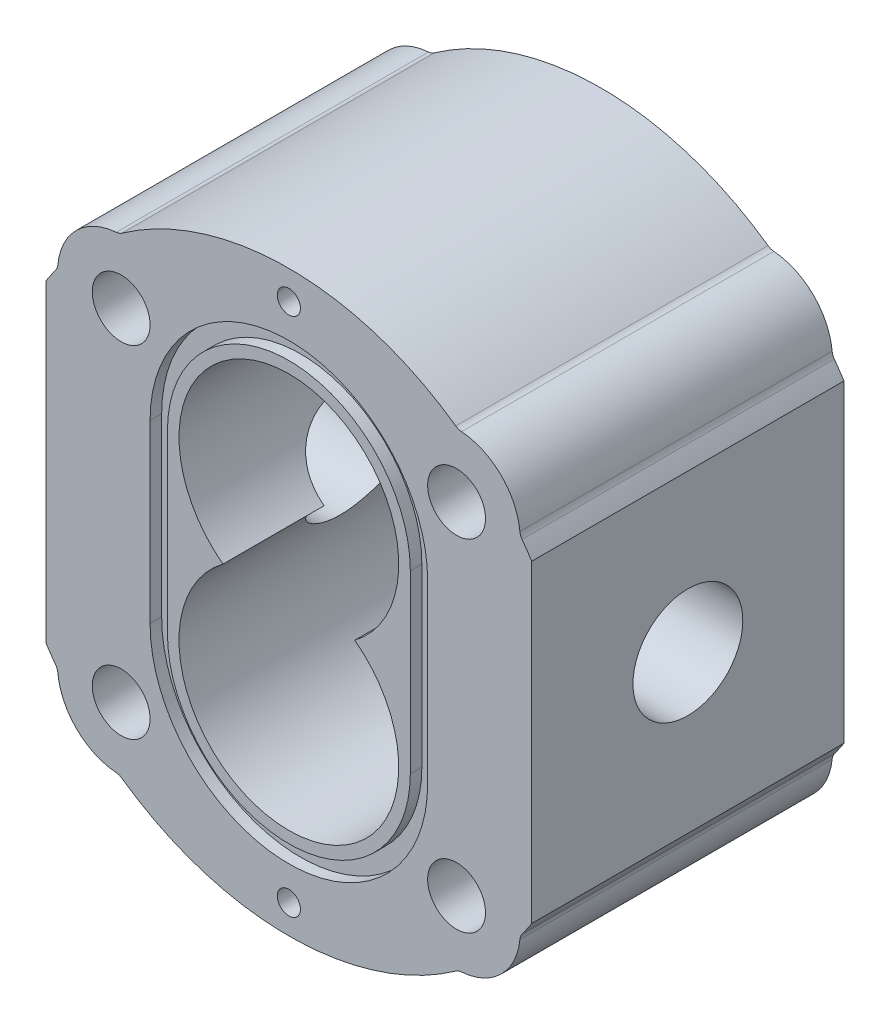
from build123d import *

# Parameters (mm, degrees)
SKETCH2_R           = 5
BOSS_EXTRUDE1_DEPTH = 27
SKETCH3_R           = 9.5
CUT_EXTRUDE2_DEPTH  = 85
CUT_EXTRUDE3_DEPTH  = 2
SKETCH6_R           = 2
CUT_EXTRUDE4_DEPTH  = 3


with BuildPart() as part:
    # Sketch2 → Boss-Extrude1 (new body, symmetric)
    with BuildSketch(Plane.XY):
        with BuildLine():
            ThreePointArc((-39.949803133, 15.349672018), (-36.711412809, 22.144368202), (-29.86235622, 25.266145255))
            ThreePointArc((-29.86235622, 25.266145255), (-29.339100999, 25.379156062), (-28.864565634, 25.626913314))
            ThreePointArc((-28.864565634, 25.626913314), (0, 34.8), (28.864565634, 25.626913314))
            ThreePointArc((28.864565634, 25.626913314), (29.339100999, 25.379156062), (29.86235622, 25.266145255))
            ThreePointArc((29.86235622, 25.266145255), (36.711412809, 22.144368202), (39.949803133, 15.349672018))
            ThreePointArc((39.949803133, 15.349672018), (40.071741311, 14.828424908), (40.32757349, 14.358193726))
            ThreePointArc((40.32757349, 14.358193726), (41.181697345, 13.15608936), (42, 11.929319933))
            Line((42, 11.929319933), (42, -42.329319933))
            ThreePointArc((42, -42.329319933), (41.181697345, -43.55608936), (40.32757349, -44.758193726))
            ThreePointArc((40.32757349, -44.758193726), (40.071741311, -45.228424908), (39.949803133, -45.749672018))
            ThreePointArc((39.949803133, -45.749672018), (36.711412809, -52.544368202), (29.86235622, -55.666145255))
            ThreePointArc((29.86235622, -55.666145255), (29.339100999, -55.779156062), (28.864565634, -56.026913314))
            ThreePointArc((28.864565634, -56.026913314), (0, -65.2), (-28.864565634, -56.026913314))
            ThreePointArc((-28.864565634, -56.026913314), (-29.339100999, -55.779156062), (-29.86235622, -55.666145255))
            ThreePointArc((-29.86235622, -55.666145255), (-36.711412809, -52.544368202), (-39.949803133, -45.749672018))
            ThreePointArc((-39.949803133, -45.749672018), (-40.071741311, -45.228424908), (-40.32757349, -44.758193726))
            ThreePointArc((-40.32757349, -44.758193726), (-41.181697345, -43.55608936), (-42, -42.329319933))
            Line((-42, -42.329319933), (-42, 11.929319933))
            ThreePointArc((-42, 11.929319933), (-41.181697345, 13.15608936), (-40.32757349, 14.358193726))
            ThreePointArc((-40.32757349, 14.358193726), (-40.071741311, 14.828424908), (-39.949803133, 15.349672018))
        make_face()
        with Locations((-29, -44.7)):
            Circle(SKETCH2_R, mode=Mode.SUBTRACT)
        with Locations((-29, 14.3)):
            Circle(SKETCH2_R, mode=Mode.SUBTRACT)
        with Locations((29, -44.7)):
            Circle(SKETCH2_R, mode=Mode.SUBTRACT)
        with Locations((29, 14.3)):
            Circle(SKETCH2_R, mode=Mode.SUBTRACT)
        with BuildLine():
            ThreePointArc((-11.4, -15.2), (0, -49.4), (11.4, -15.2))
            ThreePointArc((11.4, -15.2), (0, 19), (-11.4, -15.2))
        make_face(mode=Mode.SUBTRACT)
    extrude(amount=BOSS_EXTRUDE1_DEPTH, both=True)

    # Sketch3 → Cut-Extrude2 (cut, through all)
    with BuildSketch(Plane(origin=(42, 0, 0), x_dir=(0, 0, -1), z_dir=(1, 0, 0))):
        with Locations((0, -15.2)):
            Circle(SKETCH3_R)
    extrude(amount=-CUT_EXTRUDE2_DEPTH, mode=Mode.SUBTRACT)

    # Sketch5 → Cut-Extrude3 (cut)
    with BuildSketch(Plane(origin=(0, 0, -27), x_dir=(-1, 0, 0), z_dir=(0, 0, -1))):
        with BuildLine():
            Line((-24, 0), (-24, -30.4))
            ThreePointArc((-24, -30.4), (0, -54.4), (24, -30.4))
            Line((24, -30.4), (24, 0))
            ThreePointArc((24, 0), (0, 24), (-24, 0))
        make_face()
        with BuildLine():
            Line((-21, 0), (-21, -30.4))
            ThreePointArc((-21, -30.4), (0, -51.4), (21, -30.4))
            Line((21, -30.4), (21, 0))
            ThreePointArc((21, 0), (0, 21), (-21, 0))
        make_face(mode=Mode.SUBTRACT)
    cut_extrude3 = extrude(amount=-CUT_EXTRUDE3_DEPTH, mode=Mode.SUBTRACT)

    # Sketch6 → Cut-Extrude4 (cut)
    with BuildSketch(Plane(origin=(0, 0, -27), x_dir=(-1, 0, 0), z_dir=(0, 0, -1))):
        with Locations((0, 29.8)):
            Circle(SKETCH6_R)
        with Locations((0, -60.2)):
            Circle(SKETCH6_R)
    cut_extrude4 = extrude(amount=-CUT_EXTRUDE4_DEPTH, mode=Mode.SUBTRACT)

    # Mirror1: Cut-Extrude3, Cut-Extrude4 across plane
    add(cut_extrude3.mirror(Plane.XY), mode=Mode.SUBTRACT)
    add(cut_extrude4.mirror(Plane.XY), mode=Mode.SUBTRACT)


solid = part.part
